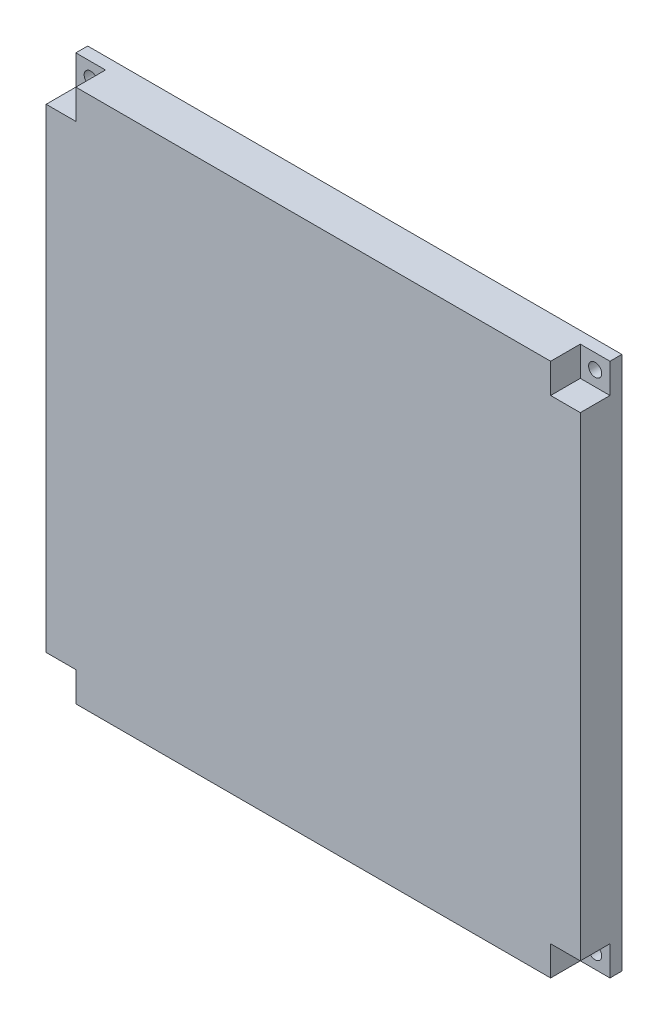
from build123d import *

# Parameters (mm, degrees)
SKETCH_1_W          = 100
SKETCH_1_H          = 90
EXTRUDE_1_DEPTH     = 10
SKETCH_6_W          = 5
SKETCH_6_H          = 5
CUT_EXTRUDE_4_DEPTH = 5
SKETCH_7_W          = 5
SKETCH_7_H          = 5
CUT_EXTRUDE_5_DEPTH = 3
SKETCH_8_R          = 1.1
CUT_EXTRUDE_6_DEPTH = 42
SKETCH_10_W         = 100
SKETCH_10_H         = 90
CUT_EXTRUDE_7_DEPTH = 3
SKETCH_11_W         = 7
SKETCH_11_H         = 90
CUT_EXTRUDE_8_DEPTH = 5
SKETCH_12_W         = 7
SKETCH_12_H         = 90
CUT_EXTRUDE_9_DEPTH = 5


with BuildPart() as part:
    # 草圖1 → 填料-伸長1 (new body)
    with BuildSketch(Plane.XY):
        with Locations((-39.08671555, -2.01863354)):
            Rectangle(SKETCH_1_W, SKETCH_1_H)
    extrude(amount=EXTRUDE_1_DEPTH)

    # 草圖6 → 除料-伸長4 (cut)
    with BuildSketch(Plane.XY.offset(10)):
        with Locations((3.41328445, 40.48136646)):
            Rectangle(SKETCH_6_W, SKETCH_6_H)
        with Locations((-81.58671555, 40.48136646)):
            Rectangle(SKETCH_6_W, SKETCH_6_H)
        with Locations((-81.58671555, -44.51863354)):
            Rectangle(SKETCH_6_W, SKETCH_6_H)
        with Locations((3.41328445, -44.51863354)):
            Rectangle(SKETCH_6_W, SKETCH_6_H)
    extrude(amount=-CUT_EXTRUDE_4_DEPTH, mode=Mode.SUBTRACT)

    # 草圖7 → 除料-伸長5 (cut)
    with BuildSketch(Plane(origin=(0, 0, 0), x_dir=(-1, 0, 0), z_dir=(0, 0, -1))):
        with Locations((81.58671555, 40.48136646)):
            Rectangle(SKETCH_7_W, SKETCH_7_H)
        with Locations((-3.41328445, 40.48136646)):
            Rectangle(SKETCH_7_W, SKETCH_7_H)
        with Locations((81.58671555, -44.51863354)):
            Rectangle(SKETCH_7_W, SKETCH_7_H)
        with Locations((-3.41328445, -44.51863354)):
            Rectangle(SKETCH_7_W, SKETCH_7_H)
    extrude(amount=-CUT_EXTRUDE_5_DEPTH, mode=Mode.SUBTRACT)

    # 草圖8 → 除料-伸長6 (cut)
    with BuildSketch(Plane(origin=(0, 0, 0), x_dir=(-1, 0, 0), z_dir=(0, 0, -1))):
        with Locations((-3.41328445, 40.48136646)):
            Circle(SKETCH_8_R)
        with Locations((81.58671555, 40.48136646)):
            Circle(SKETCH_8_R)
        with Locations((81.58671555, -44.51863354)):
            Circle(SKETCH_8_R)
        with Locations((-3.41328445, -44.51863354)):
            Circle(SKETCH_8_R)
    extrude(amount=-CUT_EXTRUDE_6_DEPTH, mode=Mode.SUBTRACT)

    # 草圖10 → 除料-伸長7 (cut)
    with BuildSketch(Plane.XY):
        with Locations((-39.08671555, -2.01863354)):
            Rectangle(SKETCH_10_W, SKETCH_10_H)
    extrude(amount=CUT_EXTRUDE_7_DEPTH, mode=Mode.SUBTRACT)

    # 草圖11 → 除料-伸長8 (cut)
    with BuildSketch(Plane(origin=(10.91328445, 0, 0), x_dir=(0, 0, -1), z_dir=(1, 0, 0))):
        with Locations((-6.5, -2.01863354)):
            Rectangle(SKETCH_11_W, SKETCH_11_H)
    extrude(amount=-CUT_EXTRUDE_8_DEPTH, mode=Mode.SUBTRACT)

    # 草圖12 → 除料-伸長9 (cut)
    with BuildSketch(Plane.ZY.offset(89.08671555)):
        with Locations((6.5, -2.01863354)):
            Rectangle(SKETCH_12_W, SKETCH_12_H)
    extrude(amount=-CUT_EXTRUDE_9_DEPTH, mode=Mode.SUBTRACT)


solid = part.part
